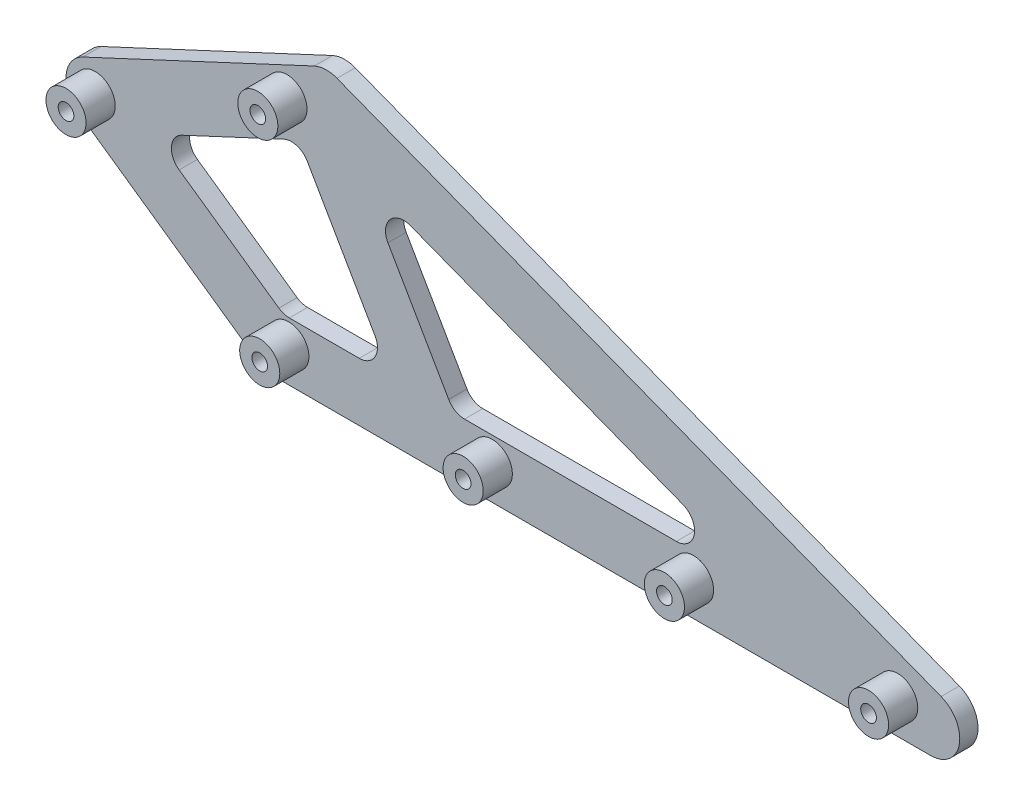
from build123d import *

# Parameters (mm, degrees)
BOSS_EXTRUDE1_DEPTH = 5
BOSS_EXTRUDE2_DEPTH = 5
FILLET1_R           = 5
SKETCH3_R           = 5.5
SKETCH3_R_2         = 2.15
BOSS_EXTRUDE3_DEPTH = 8
SKETCH4_R           = 2.15
CUT_EXTRUDE1_DEPTH  = 6


with BuildPart() as part:
    # Sketch1 → Boss-Extrude1 (new body)
    with BuildSketch(Plane.XY):
        with BuildLine():
            Line((-44.560511167, 40.967802535), (-33.210007488, 33.020094297))
            Line((-33.210007488, 33.020094297), (14.586986289, 55.308198532))
            Line((14.586986289, 55.308198532), (11.410228171, 56.535093153))
            ThreePointArc((11.410228171, 56.535093153), (6.297014824, 63.726834744), (10.911476341, 71.248326799))
            Line((10.911476341, 71.248326799), (-52.530068751, 41.665048477))
            ThreePointArc((-52.530068751, 41.665048477), (-48.451876715, 42.384143766), (-44.560511167, 40.967802535))
        make_face()
        with BuildLine():
            Line((14.586986289, 55.308198532), (137.080557575, 8))
            Line((137.080557575, 8), (180, 8))
            ThreePointArc((180, 8), (181.465917665, 7.864546103), (182.882194265, 7.46277135))
            Line((182.882194265, 7.46277135), (17.1746167, 71.460635853))
            ThreePointArc((17.1746167, 71.460635853), (22.287830046, 64.268894262), (17.673368529, 56.747402207))
            Line((17.673368529, 56.747402207), (14.586986289, 55.308198532))
        make_face()
        with BuildLine():
            Line((137.080557575, 8), (2.522390311, 8))
            Line((2.522390311, 8), (4.588611491, 6.553216354))
            ThreePointArc((4.588611491, 6.553216354), (7.629735606, -2.405646396), (0, -8))
            Line((0, -8), (180, -8))
            ThreePointArc((180, -8), (178.534082335, -7.864546103), (177.117805735, -7.46277135))
            Line((177.117805735, -7.46277135), (137.080557575, 8))
        make_face()
        with BuildLine():
            ThreePointArc((-4.588611491, -6.553216354), (-7.629735606, 2.405646396), (0, 8))
            Line((0, 8), (2.522390311, 8))
            Line((2.522390311, 8), (-33.210007488, 33.020094297))
            Line((-33.210007488, 33.020094297), (-45.768176563, 27.164123885))
            ThreePointArc((-45.768176563, 27.164123885), (-49.846368599, 26.445028596), (-53.737734148, 27.861369827))
            Line((-53.737734148, 27.861369827), (-4.588611491, -6.553216354))
        make_face()
        with BuildLine():
            Line((180, 8), (137.080557575, 8))
            Line((137.080557575, 8), (177.117805735, -7.46277135))
            ThreePointArc((177.117805735, -7.46277135), (178.534082335, -7.864546103), (180, -8))
            ThreePointArc((180, -8), (187.864546103, -1.465917665), (182.882194265, 7.46277135))
            ThreePointArc((182.882194265, 7.46277135), (181.465917665, 7.864546103), (180, 8))
        make_face()
        with BuildLine():
            Line((11.410228171, 56.535093153), (14.586986289, 55.308198532))
            Line((14.586986289, 55.308198532), (17.673368529, 56.747402207))
            ThreePointArc((17.673368529, 56.747402207), (22.287830046, 64.268894262), (17.1746167, 71.460635853))
            ThreePointArc((17.1746167, 71.460635853), (14.021392676, 71.993272114), (10.911476341, 71.248326799))
            ThreePointArc((10.911476341, 71.248326799), (6.297014824, 63.726834744), (11.410228171, 56.535093153))
        make_face()
        with BuildLine():
            Line((-45.768176563, 27.164123885), (-33.210007488, 33.020094297))
            Line((-33.210007488, 33.020094297), (-44.560511167, 40.967802535))
            ThreePointArc((-44.560511167, 40.967802535), (-48.451876715, 42.384143766), (-52.530068751, 41.665048477))
            ThreePointArc((-52.530068751, 41.665048477), (-57.118680242, 35.111832123), (-53.737734148, 27.861369827))
            ThreePointArc((-53.737734148, 27.861369827), (-49.846368599, 26.445028596), (-45.768176563, 27.164123885))
        make_face()
        with BuildLine():
            Line((2.522390311, 8), (0, 8))
            ThreePointArc((0, 8), (-7.629735606, 2.405646396), (-4.588611491, -6.553216354))
            ThreePointArc((-4.588611491, -6.553216354), (-2.405646396, -7.629735606), (0, -8))
            ThreePointArc((0, -8), (7.629735606, -2.405646396), (4.588611491, 6.553216354))
            Line((4.588611491, 6.553216354), (2.522390311, 8))
        make_face()
    extrude(amount=BOSS_EXTRUDE1_DEPTH)

    # Sketch2 → Boss-Extrude2 (add, through all)
    with BuildSketch(Plane.XY.offset(5)):
        Polygon((14.586986289, 55.308198532), (6.740403892, 51.64927707), (31.941325759, 8), (49.261833834, 8), (24.060911968, 51.64927707), align=None)
    extrude(amount=-BOSS_EXTRUDE2_DEPTH)

    # Fillet1
    fillet1_edges = [part.edges().sort_by_distance(p)[0] for p in [
        (-33.210007488, 33.020094297, 2.5),
        (2.522390311, 8, 2.5),
        (137.080557575, 8, 2.5),
        (24.060911968, 51.64927707, 2.5),
        (49.261833834, 8, 2.5),
        (31.941325759, 8, 2.5),
        (6.740403892, 51.64927707, 2.5),
    ]]
    fillet(fillet1_edges, radius=FILLET1_R)

    # Sketch3 → Boss-Extrude3 (add)
    with BuildSketch(Plane.XY.offset(5)):
        with Locations((-49.149122657, 34.414586181)):
            Circle(SKETCH3_R)
        with Locations((-49.149122657, 34.414586181)):
            Circle(SKETCH3_R_2, mode=Mode.SUBTRACT)
        with Locations((3.981659537, 1.5)):
            Circle(SKETCH3_R)
        with Locations((3.981659537, 1.5)):
            Circle(SKETCH3_R_2, mode=Mode.SUBTRACT)
        with Locations((59.781659537, 1.5)):
            Circle(SKETCH3_R)
        with Locations((59.781659537, 1.5)):
            Circle(SKETCH3_R_2, mode=Mode.SUBTRACT)
        with Locations((114.981659537, 1.5)):
            Circle(SKETCH3_R)
        with Locations((114.981659537, 1.5)):
            Circle(SKETCH3_R_2, mode=Mode.SUBTRACT)
        with Locations((170.981659537, 1.5)):
            Circle(SKETCH3_R)
        with Locations((170.981659537, 1.5)):
            Circle(SKETCH3_R_2, mode=Mode.SUBTRACT)
        with Locations((3.45920938, 60)):
            Circle(SKETCH3_R)
        with Locations((3.45920938, 60)):
            Circle(SKETCH3_R_2, mode=Mode.SUBTRACT)
    extrude(amount=BOSS_EXTRUDE3_DEPTH)

    # Sketch4 → Cut-Extrude1 (cut, through all)
    with BuildSketch(Plane.XY.offset(5)):
        with Locations((-49.149122657, 34.414586181)):
            Circle(SKETCH4_R)
        with Locations((3.981659537, 1.5)):
            Circle(SKETCH4_R)
        with Locations((59.781659537, 1.5)):
            Circle(SKETCH4_R)
        with Locations((114.981659537, 1.5)):
            Circle(SKETCH4_R)
        with Locations((170.981659537, 1.5)):
            Circle(SKETCH4_R)
        with Locations((3.45920938, 60)):
            Circle(SKETCH4_R)
    extrude(amount=-CUT_EXTRUDE1_DEPTH, mode=Mode.SUBTRACT)


solid = part.part
